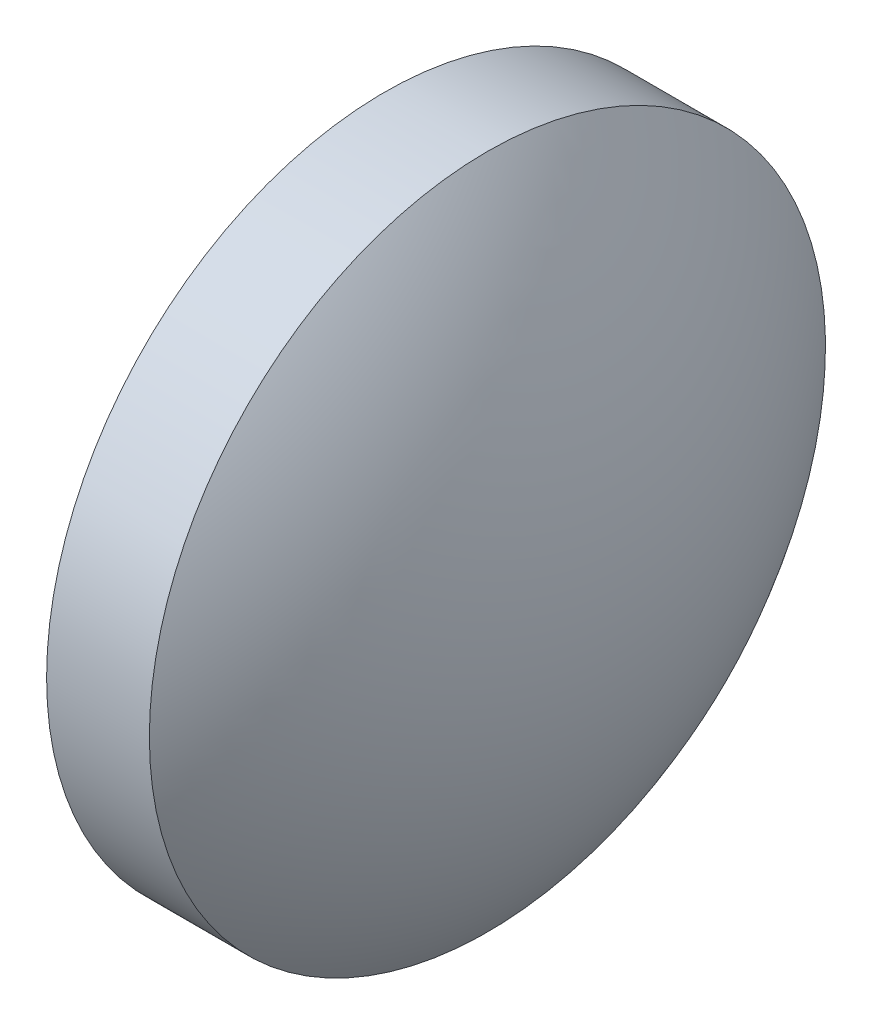
from build123d import *


with BuildPart() as part:
    # 草图1 → 旋转1 (revolve)
    with BuildSketch(Plane.XY):
        with BuildLine():
            Line((553.707939458, 146.784706945), (553.707939458, 151.784706945))
            Line((553.707939458, 151.784706945), (555.227939458, 151.784706945))
            ThreePointArc((555.227939458, 151.784706945), (556.476710744, 149.422054097), (556.907939458, 146.784706945))
            Line((556.907939458, 146.784706945), (553.707939458, 146.784706945))
        make_face()
    revolve(axis=Axis((552.766388986, 146.784706945, 0), (1, 0, 0)))


solid = part.part
